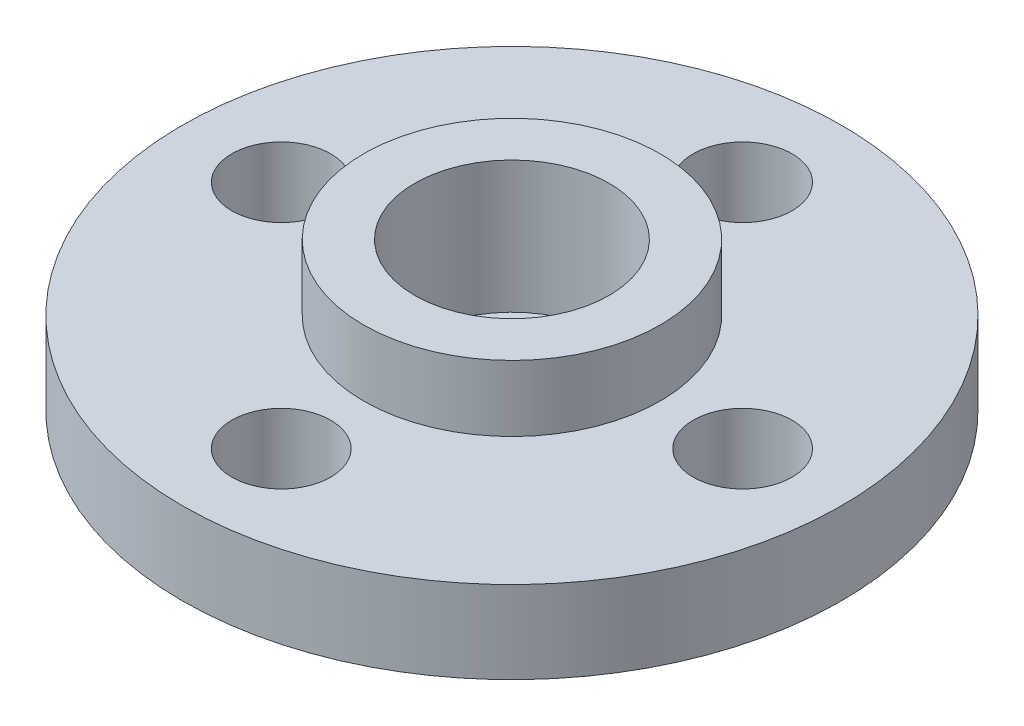
from build123d import *

# Parameters (mm, degrees)
IZIM1_R                     = 10
IZIM1_R_2                   = 1.5
Y_KSEKLIK_EKSTR_ZYON1_DEPTH = 2.5
IZIM2_R                     = 4.5
IZIM2_R_2                   = 2.95
Y_KSEKLIK_EKSTR_ZYON2_DEPTH = 2
IZIM3_R                     = 1.6
KES_EKSTR_ZYON1_DEPTH       = 3.5
IZIM4_R                     = 2.95
IZIM4_R_2                   = 1.6
KES_EKSTR_ZYON2_DEPTH       = 2


with BuildPart() as part:
    # Çizim1 → Yükseklik-Ekstrüzyon1 (new body)
    with BuildSketch(Plane(origin=(0, 0, 0), x_dir=(1, 0, 0), z_dir=(0, 1, 0))):
        Circle(IZIM1_R)
        with Locations((0, 7)):
            Circle(IZIM1_R_2, mode=Mode.SUBTRACT)
        with Locations((7, 0)):
            Circle(IZIM1_R_2, mode=Mode.SUBTRACT)
        with Locations((0, -7)):
            Circle(IZIM1_R_2, mode=Mode.SUBTRACT)
        with Locations((-7, 0)):
            Circle(IZIM1_R_2, mode=Mode.SUBTRACT)
    extrude(amount=Y_KSEKLIK_EKSTR_ZYON1_DEPTH)

    # Çizim2 → Yükseklik-Ekstrüzyon2 (add)
    with BuildSketch(Plane(origin=(0, 2.5, 0), x_dir=(1, 0, 0), z_dir=(0, 1, 0))):
        Circle(IZIM2_R)
        Circle(IZIM2_R_2, mode=Mode.SUBTRACT)
    extrude(amount=Y_KSEKLIK_EKSTR_ZYON2_DEPTH)

    # Çizim3 → Kes-Ekstrüzyon1 (cut, through all)
    with BuildSketch(Plane(origin=(0, 2.5, 0), x_dir=(1, 0, 0), z_dir=(0, 1, 0))):
        Circle(IZIM3_R)
    extrude(amount=-KES_EKSTR_ZYON1_DEPTH, mode=Mode.SUBTRACT)

    # Çizim4 → Kes-Ekstrüzyon2 (cut)
    with BuildSketch(Plane(origin=(0, 2.5, 0), x_dir=(1, 0, 0), z_dir=(0, 1, 0))):
        Circle(IZIM4_R)
        Circle(IZIM4_R_2, mode=Mode.SUBTRACT)
    extrude(amount=-KES_EKSTR_ZYON2_DEPTH, mode=Mode.SUBTRACT)


solid = part.part
